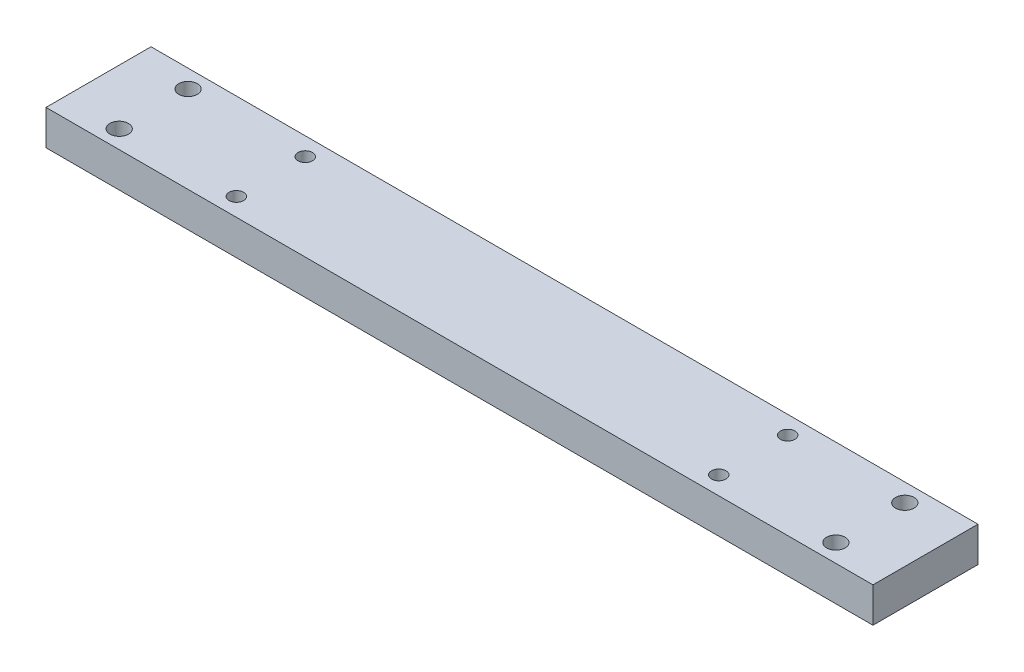
from build123d import *

# Parameters (mm, degrees)
SKETCH1_W           = 600
SKETCH1_H           = 76.2
BOSS_EXTRUDE1_DEPTH = 25.4
SKETCH2_R           = 6.75
CUT_EXTRUDE1_DEPTH  = 25.4
SKETCH3_R           = 5.25
CUT_EXTRUDE2_DEPTH  = 25.4


with BuildPart() as part:
    # Sketch1 → Boss-Extrude1 (new body)
    with BuildSketch(Plane(origin=(0, 0, 0), x_dir=(1, 0, 0), z_dir=(0, 1, 0))):
        with Locations((300, 38.1)):
            Rectangle(SKETCH1_W, SKETCH1_H)
    extrude(amount=BOSS_EXTRUDE1_DEPTH)

    # Sketch2 → Cut-Extrude1 (cut)
    with BuildSketch(Plane(origin=(0, 25.4, 0), x_dir=(1, 0, 0), z_dir=(0, 1, 0))):
        with Locations((40, 63.1)):
            Circle(SKETCH2_R)
        with Locations((40, 13.1)):
            Circle(SKETCH2_R)
        with Locations((560, 13.1)):
            Circle(SKETCH2_R)
        with Locations((560, 63.1)):
            Circle(SKETCH2_R)
    extrude(amount=-CUT_EXTRUDE1_DEPTH, mode=Mode.SUBTRACT)

    # Sketch3 → Cut-Extrude2 (cut)
    with BuildSketch(Plane(origin=(0, 25.4, 0), x_dir=(1, 0, 0), z_dir=(0, 1, 0))):
        with Locations((125, 63.1)):
            Circle(SKETCH3_R)
        with Locations((125, 13.1)):
            Circle(SKETCH3_R)
        with Locations((475, 13.1)):
            Circle(SKETCH3_R)
        with Locations((475, 63.1)):
            Circle(SKETCH3_R)
    extrude(amount=-CUT_EXTRUDE2_DEPTH, mode=Mode.SUBTRACT)


solid = part.part
